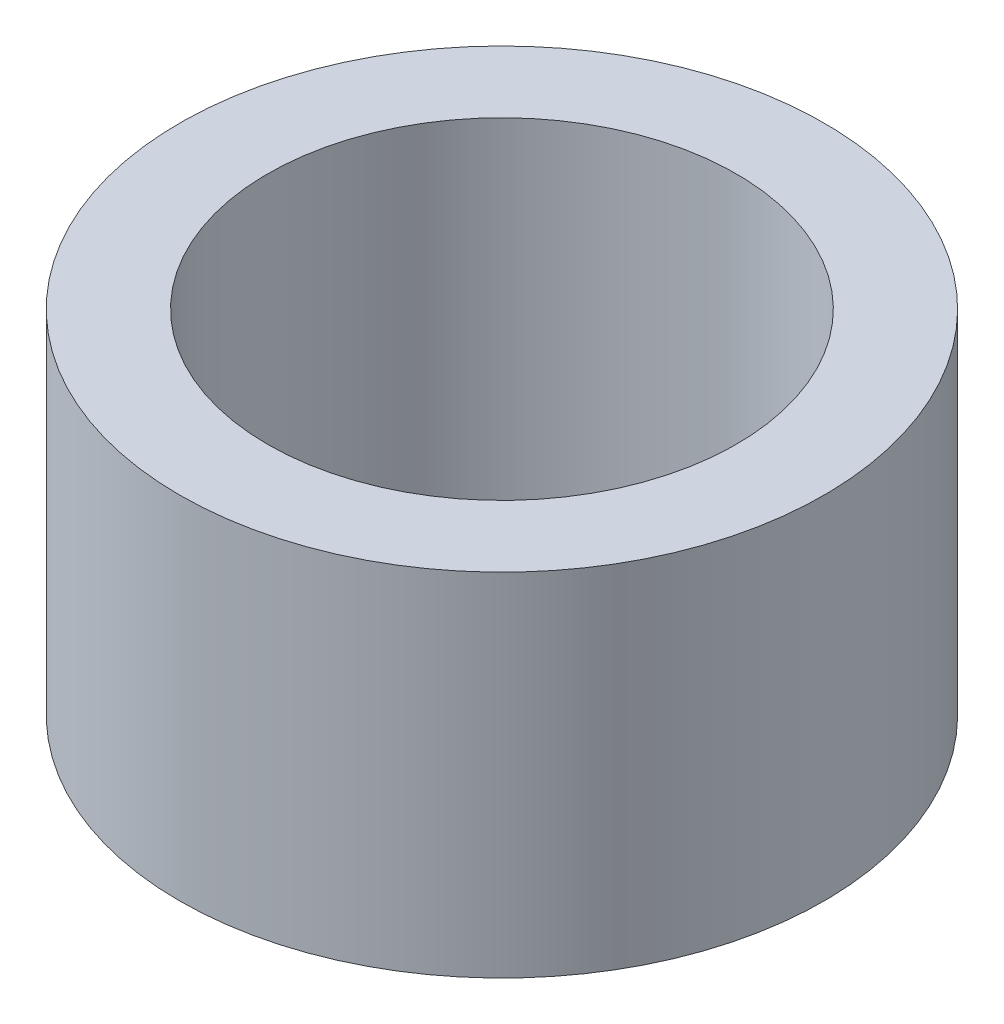
from build123d import *

# Parameters (mm, degrees)
SKETCH1_R           = 2.75
SKETCH1_R_2         = 2
BOSS_EXTRUDE1_DEPTH = 3


with BuildPart() as part:
    # Sketch1 → Boss-Extrude1 (new body)
    with BuildSketch(Plane(origin=(0, 0, 0), x_dir=(1, 0, 0), z_dir=(0, 1, 0))):
        Circle(SKETCH1_R)
        Circle(SKETCH1_R_2, mode=Mode.SUBTRACT)
    extrude(amount=BOSS_EXTRUDE1_DEPTH)


solid = part.part
